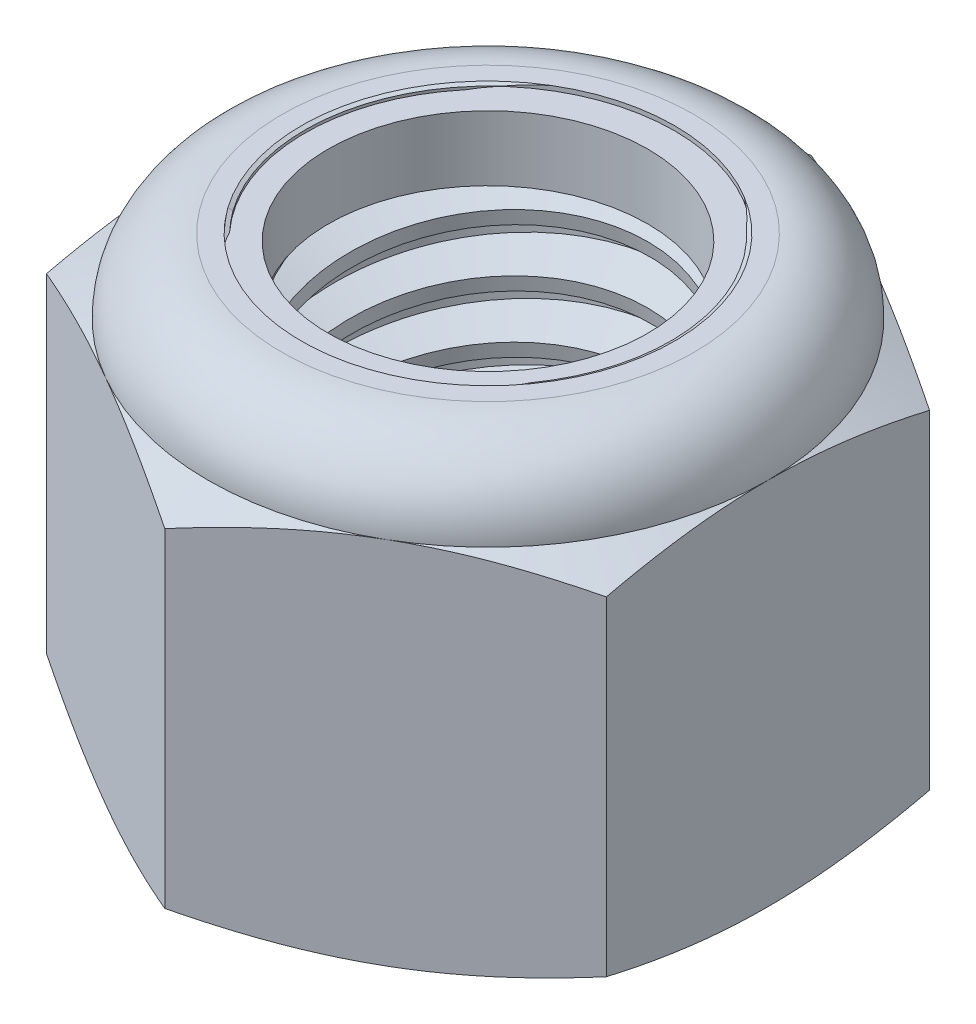
from build123d import *

# Parameters (mm, degrees)
EXTRUDE1_DEPTH      = 15.08125
SKETCH2_W           = 6.35
SKETCH2_H           = 15.08125
LPATTERN1_COUNT     = 8
LPATTERN1_PITCH     = 1.953846154
LPATTERN1_COL_COUNT = 2
LPATTERN1_COL_PITCH = 1.953846154


with BuildPart() as part:
    # Sketch1 → Extrude1 (new body)
    with BuildSketch(Plane(origin=(0, 0, 0), x_dir=(1, 0, 0), z_dir=(0, 1, 0))):
        Polygon((0, 10.998522628), (-9.525, 5.499261314), (-9.525, -5.499261314), (0, -10.998522628), (9.525, -5.499261314), (9.525, 5.499261314), align=None)
    extrude(amount=EXTRUDE1_DEPTH)

    # Sketch4 → Cut-Revolve2 (revolve, cut)
    with BuildSketch(Plane(origin=(0, 0, 0), x_dir=(0, 0, -1), z_dir=(1, 0, 0))):
        Polygon((0, 15.08125), (6.35, 15.08125), (5.434726912, 14.65445115), (5.434726912, 0.42679885), (6.35, 0), (0, 0), align=None)
    revolve(axis=Axis((0, 15.08125, 0), (0, 1, 0)), mode=Mode.SUBTRACT)


with BuildPart() as body_2:
    # Sketch2 → Revolve1 (revolve)
    with BuildSketch(Plane(origin=(0, 0, 0), x_dir=(0, 0, -1), z_dir=(1, 0, 0))):
        with Locations((3.175, 7.540625)):
            Rectangle(SKETCH2_W, SKETCH2_H)
    revolve(axis=Axis((0, -6.35, 0), (0, 1, 0)))

    # Sketch3 → Cut-Revolve1 (revolve, cut)
    with BuildSketch(Plane(origin=(0, 0, 0), x_dir=(0, 0, -1), z_dir=(1, 0, 0))):
        Polygon((6.387137043, 14.83985922), (6.647096345, 13.15012376), (5.509000998, 13.592792596), (5.434726912, 14.075574156), align=None)
    cut_revolve1 = revolve(axis=Axis((0, 15.08125, 0.321367977), (0, -0.988371698, -0.152057184)), mode=Mode.SUBTRACT)

    # LPattern1: Cut-Revolve1 ×8
    with Locations(*[(0, -i * LPATTERN1_PITCH, 0) for i in range(1, LPATTERN1_COUNT)]):
        add(cut_revolve1, mode=Mode.SUBTRACT)

    # LPattern1 col: Cut-Revolve1 ×2
    with Locations(*[(0, i * LPATTERN1_COL_PITCH, 0) for i in range(1, LPATTERN1_COL_COUNT)]):
        add(cut_revolve1, mode=Mode.SUBTRACT)


with BuildPart() as part_1:
    add(part.part)

    # Combine1: cut body 2
    add(body_2.part, mode=Mode.SUBTRACT)

    # Sketch5 → Cut-Revolve3 (revolve, cut)
    with BuildSketch(Plane(origin=(0, 0, 0), x_dir=(0, 0, -1), z_dir=(1, 0, 0))):
        with BuildLine():
            Line((0, 0), (9.525, 0))
            Line((9.525, 0), (10.998522628, 0.687114886))
            Line((10.998522628, 0.687114886), (10.998522628, 11.880593447))
            Line((10.998522628, 11.880593447), (9.525, 12.567708333))
            ThreePointArc((9.525, 12.567708333), (8.788800691, 14.345050691), (7.011458333, 15.08125))
            Line((7.011458333, 15.08125), (7.011458333, 16.35125))
            Line((7.011458333, 16.35125), (12.268522628, 16.35125))
            Line((12.268522628, 16.35125), (12.268522628, -1.27))
            Line((12.268522628, -1.27), (0, -1.27))
            Line((0, -1.27), (0, 0))
        make_face()
    revolve(axis=Axis((0, 0, 0), (0, 1, 0)), mode=Mode.SUBTRACT)

    # Sketch6 → Cut-Revolve4 (revolve, cut)
    with BuildSketch(Plane(origin=(0, 0, 0), x_dir=(0, 0, -1), z_dir=(1, 0, 0))):
        with BuildLine():
            Line((0, 12.567708333), (9.3726, 12.567708333))
            ThreePointArc((9.3726, 12.567708333), (8.681037617, 14.237287617), (7.011458333, 14.92885))
            Line((7.011458333, 14.92885), (6.223092623, 14.92885))
            Line((6.223092623, 14.92885), (6.223092623, 16.35125))
            Line((6.223092623, 16.35125), (0, 16.35125))
            Line((0, 16.35125), (0, 12.567708333))
        make_face()
    revolve(axis=Axis((0, 16.35125, 0), (0, 1, 0)), mode=Mode.SUBTRACT)


with BuildPart() as body_2_2:
    # Sketch7 → Revolve2 (revolve)
    with BuildSketch(Plane(origin=(0, 0, 0), x_dir=(0, 0, -1), z_dir=(1, 0, 0))):
        with BuildLine():
            Line((5.434726912, 12.643908333), (9.295129058, 12.643908333))
            ThreePointArc((9.295129058, 12.643908333), (8.599986877, 14.210125907), (7.011458333, 14.85265))
            Line((7.011458333, 14.85265), (5.434726912, 14.85265))
            Line((5.434726912, 14.85265), (5.434726912, 12.643908333))
        make_face()
    revolve(axis=Axis((0, 12.643908333, 0), (0, 1, 0)))


solid = Compound([part_1.part, body_2_2.part])
